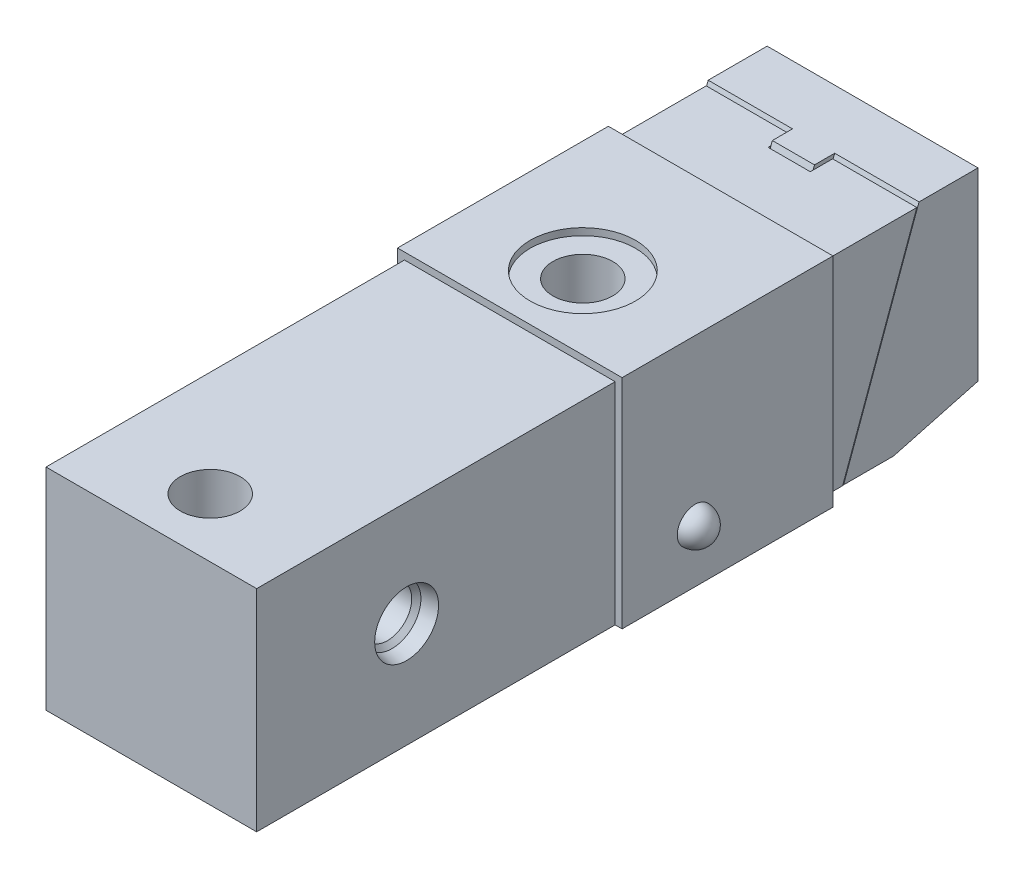
from build123d import *

# Parameters (mm, degrees)
SKETCH1_W          = 73.9902
SKETCH1_H          = 29.972
EXTRUDE1_DEPTH     = 14.986
EXTRUDE4_DEPTH     = 14.99997
EXTRUDE5_DEPTH     = 2.999994
SKETCH14_R         = 3.5052
EXTRUDE6_DEPTH     = 3.247898
CUT_EXTRUDE3_DEPTH = 3.247898
EXTRUDE2_DEPTH     = 14.986
CUT_EXTRUDE1_DEPTH = 2.9972
SKETCH4_R          = 4.2545
CUT_EXTRUDE2_DEPTH = 29.972
HOLE1_AT_2_COUNT   = 2
HOLE1_AT_2_PITCH   = 59.0042
HOLE1_AT_3_COUNT   = 2
HOLE1_AT_3_PITCH   = 22.098
HOLE1_AT_4_COUNT   = 2
HOLE1_AT_4_PITCH   = 63.006485552
SKETCH8_R          = 1.0033
EXTRUDE3_DEPTH     = 29.9974
SKETCH18_R         = 7.493
CUT_EXTRUDE4_DEPTH = 0.9906


with BuildPart() as part:
    # Sketch1 → Extrude1 (new body, symmetric)
    with BuildSketch(Plane(origin=(0, 0, 0), x_dir=(0, 0, -1), z_dir=(1, 0, 0))):
        with Locations((36.9951, 14.986)):
            Rectangle(SKETCH1_W, SKETCH1_H)
    extrude(amount=EXTRUDE1_DEPTH, both=True)

    # Sketch4 → Cut-Extrude2 (cut)
    with BuildSketch(Plane.XZ):
        with Locations(Location((0, -8.382, 0), (0, 0, 270))):  # turned: the seam where the file's is
            Circle(SKETCH4_R)
        with Locations(Location((0, -61.3918, 0), (0, 0, 270))):  # turned: the seam where the file's is
            Circle(SKETCH4_R)
    extrude(amount=-CUT_EXTRUDE2_DEPTH, mode=Mode.SUBTRACT)

    # Sketch16 → Hole1 (revolve, cut)
    with BuildSketch(Plane(origin=(-11.049, 0, -8.382), x_dir=(0, 0, -1), z_dir=(1, 0, 0))):
        Polygon((0, 0), (0, 7.599293183), (2.5019, 6.096), (2.5019, 0), align=None)
    hole1 = revolve(axis=Axis((-11.049, -4.244199587, -8.382), (0, 1, 0)), mode=Mode.SUBTRACT)

    # Hole1 at 2: Hole1 ×2
    with Locations(*[(0, 0, -i * HOLE1_AT_2_PITCH) for i in range(1, HOLE1_AT_2_COUNT)]):
        add(hole1, mode=Mode.SUBTRACT)

    # Hole1 at 3: Hole1 ×2
    with Locations(*[(i * HOLE1_AT_3_PITCH, 0, 0) for i in range(1, HOLE1_AT_3_COUNT)]):
        add(hole1, mode=Mode.SUBTRACT)

    # Hole1 at 4: Hole1 ×2
    with Locations(*[Vector(0.350725799, 0, -0.936478197) * (i * HOLE1_AT_4_PITCH) for i in range(1, HOLE1_AT_4_COUNT)]):
        add(hole1, mode=Mode.SUBTRACT)

    # S2D0001 → Cut-Revolve2 (revolve, cut)
    with BuildSketch(Plane(origin=(14.986, 14.986, -21.336), x_dir=(0, 0, -1), z_dir=(0, -1, 0)), mode=Mode.PRIVATE) as cut_revolve2_sk:
        Polygon((0, 0), (4.5466, 0), (4.106586662, -2.0701), (3.4544, -2.722286662), (3.4544, -15.24), (0, -15.24), align=None)
    cut_revolve2 = revolve(cut_revolve2_sk.sketch.rotate(Axis((-10.40039223, 14.986, -21.336), (1, 0, 0)), 180), axis=Axis((-10.40039223, 14.986, -21.336), (1, 0, 0)), mode=Mode.SUBTRACT)  # turned: the seam where the file's is

    # Mirror1: Cut-Revolve2 across plane
    add(cut_revolve2.mirror(Plane(origin=(0, 0, 0), x_dir=(0, 0, 1), z_dir=(1, 0, 0))), mode=Mode.SUBTRACT)

    # Sketch19 → Cut-Revolve5 (revolve, cut)
    with BuildSketch(Plane(origin=(0, 0, 0), x_dir=(0, 0, -1), z_dir=(1, 0, 0)), mode=Mode.PRIVATE) as cut_revolve5_sk:
        Polygon((25.654, 0), (25.654, 1.5875), (23.8379, 1.5875), (23.8379, 14.986), (21.336, 14.986), (21.336, 0), align=None)
    revolve(cut_revolve5_sk.sketch.rotate(Axis((0, 14.986, -21.336), (0, -1, 0)), 180), axis=Axis((0, 14.986, -21.336), (0, -1, 0)), mode=Mode.SUBTRACT)  # turned: the seam where the file's is


with BuildPart() as body_2:
    # Sketch11 → Extrude4 (new body, symmetric)
    with BuildSketch(Plane(origin=(0, 0, 0), x_dir=(0, 0, -1), z_dir=(1, 0, 0))):
        Polygon((94.22638, 30.516068), (102.616, 30.516068), (102.616, 4.231386), (90.616016082, 1.016), (83.489233339, 1.016), align=None)
    extrude(amount=EXTRUDE4_DEPTH, both=True)

    # Sketch12 → Extrude5 (add, symmetric)
    with BuildSketch(Plane(origin=(0, 0, 0), x_dir=(0, 0, -1), z_dir=(1, 0, 0))):
        Polygon((94.22638, 30.516068), (83.489233339, 1.016), (80.61593207, 1.016), (91.353078731, 30.516068), align=None)
    extrude(amount=EXTRUDE5_DEPTH, both=True)

    # Sketch13 → Cut-Revolve4 (revolve, cut)
    with BuildSketch(Plane(origin=(0, 0, 0), x_dir=(0, 0, -1), z_dir=(1, 0, 0)), mode=Mode.PRIVATE) as cut_revolve4_sk:
        Polygon((102.616, 19.51609), (97.815908, 19.51609), (97.815908, 17.666081), (95.815912, 17.666081), (95.815912, 24.016081), (76.765912, 24.016081), (76.765912, 15.516098), (102.616, 15.516098), align=None)
    revolve(cut_revolve4_sk.sketch.rotate(Axis((0, 15.516098, -76.857343905), (0, 0, -1)), 90), axis=Axis((0, 15.516098, -76.857343905), (0, 0, -1)), mode=Mode.SUBTRACT)  # turned: the seam where the file's is

    # Sketch14 → Extrude6 (add)
    with BuildSketch(Plane(origin=(0, 0, -97.815908), x_dir=(-1, 0, 0), z_dir=(0, 0, -1))):
        with Locations((0, 15.516098)):
            Circle(SKETCH14_R)
    extrude(amount=EXTRUDE6_DEPTH)

    # Sketch15 → Cut-Extrude3 (cut)
    with BuildSketch(Plane(origin=(0, 0, -101.063806), x_dir=(-1, 0, 0), z_dir=(0, 0, -1))):
        Polygon((2.302357403, 15.516098), (1.151178702, 17.509998), (-1.151178702, 17.509998), (-2.302357403, 15.516098), (-1.151178702, 13.522198), (1.151178702, 13.522198), align=None)
    extrude(amount=-CUT_EXTRUDE3_DEPTH, mode=Mode.SUBTRACT)


with BuildPart() as body_3:
    # Sketch2 → Extrude2 (new body, symmetric)
    with BuildSketch(Plane(origin=(0, 0, 0), x_dir=(0, 0, -1), z_dir=(1, 0, 0))):
        Polygon((77.9018, 29.972), (77.9018, 0.9652), (83.371588209, 0.9652), (93.9292, 29.972), align=None)
    extrude(amount=EXTRUDE2_DEPTH, both=True)

    # Sketch3 → Cut-Extrude1 (cut, symmetric)
    with BuildSketch(Plane(origin=(0, 0, 0), x_dir=(0, 0, -1), z_dir=(1, 0, 0))):
        Polygon((90.7542, 29.972), (80.196588209, 0.9652), (83.371588209, 0.9652), (93.9292, 29.972), align=None)
    extrude(amount=CUT_EXTRUDE1_DEPTH, both=True, mode=Mode.SUBTRACT)


with BuildPart() as body_4:
    # Sketch8 → Revolve1 (revolve)
    with BuildSketch(Plane(origin=(0, 0, 0), x_dir=(0, 0, -1), z_dir=(1, 0, 0)), mode=Mode.PRIVATE) as revolve1_sk:
        with Locations((24.6507, 0.5842)):
            Circle(SKETCH8_R)
    revolve(revolve1_sk.sketch.rotate(Axis((0, -0.51943, -21.336), (0, 1, 0)), 180), axis=Axis((0, -0.51943, -21.336), (0, 1, 0)))  # turned: the seam where the file's is


with BuildPart() as body_5:
    # Sketch9 → Extrude3 (new body)
    with BuildSketch(Plane(origin=(0, 0, -81.0006), x_dir=(-1, 0, 0), z_dir=(0, 0, -1))):
        Polygon((14.986, 29.972), (14.986, 0), (15.9766, 0), (15.9766, 30.9626), (-15.9766, 30.9626), (-15.9766, 0), (-14.986, 0), (-14.986, 29.972), align=None)
    extrude(amount=-EXTRUDE3_DEPTH)

    # Sketch10 → Revolve2 (revolve)
    with BuildSketch(Plane(origin=(0, 7.62, -83.7438), x_dir=(1, 0, 0), z_dir=(0, 1, 0))):
        with BuildLine():
            Line((15.9766, -19.812), (15.9766, -22.352))
            Line((15.9766, -22.352), (18.5166, -22.352))
            ThreePointArc((18.5166, -22.352), (17.772651224, -20.555948776), (15.9766, -19.812))
        make_face()
        with BuildLine():
            Line((-15.9766, -19.812), (-15.9766, -22.352))
            Line((-15.9766, -22.352), (-18.5166, -22.352))
            ThreePointArc((-18.5166, -22.352), (-17.772651224, -20.555948776), (-15.9766, -19.812))
        make_face()
    revolve(axis=Axis((-20.36826, 7.62, -61.3918), (1, 0, 0)))

    # Sketch18 → Cut-Extrude4 (cut)
    with BuildSketch(Plane(origin=(0, 30.9626, 0), x_dir=(1, 0, 0), z_dir=(0, 1, 0))):
        with Locations(Location((0, 61.3918, 0), (0, 0, 180))):  # turned: the seam where the file's is
            Circle(SKETCH18_R)
    extrude(amount=-CUT_EXTRUDE4_DEPTH, mode=Mode.SUBTRACT)


solid = Compound([part.part, body_2.part, body_3.part, body_4.part, body_5.part])
